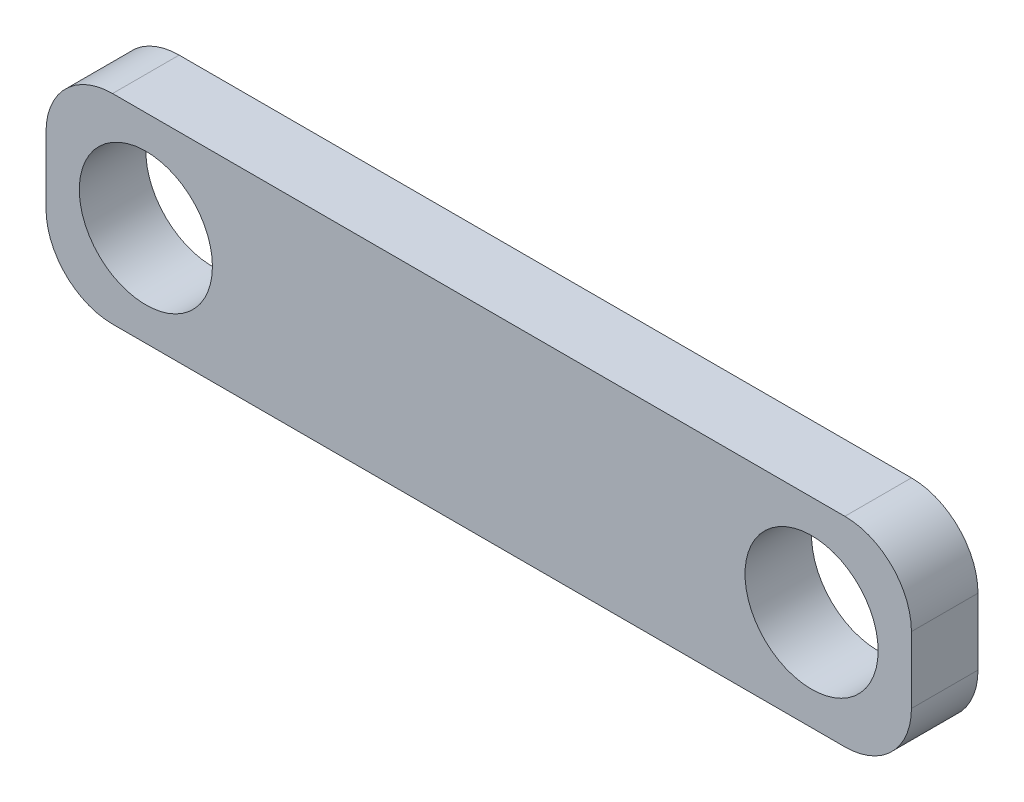
from build123d import *

# Parameters (mm, degrees)
CROQUIS1_R              = 10
SALIENTE_EXTRUIR1_DEPTH = 5


with BuildPart() as part:
    # Croquis1 → Saliente-Extruir1 (new body, symmetric)
    with BuildSketch(Plane.XY):
        with BuildLine():
            Line((-55, 15), (55, 15))
            ThreePointArc((55, 15), (62.071067812, 12.071067812), (65, 5))
            Line((65, 5), (65, -5))
            ThreePointArc((65, -5), (62.071067812, -12.071067812), (55, -15))
            Line((55, -15), (-55, -15))
            ThreePointArc((-55, -15), (-62.071067812, -12.071067812), (-65, -5))
            Line((-65, -5), (-65, 5))
            ThreePointArc((-65, 5), (-62.071067812, 12.071067812), (-55, 15))
        make_face()
        with Locations((-50, 0)):
            Circle(CROQUIS1_R, mode=Mode.SUBTRACT)
        with Locations((50, 0)):
            Circle(CROQUIS1_R, mode=Mode.SUBTRACT)
    extrude(amount=SALIENTE_EXTRUIR1_DEPTH, both=True)


solid = part.part
